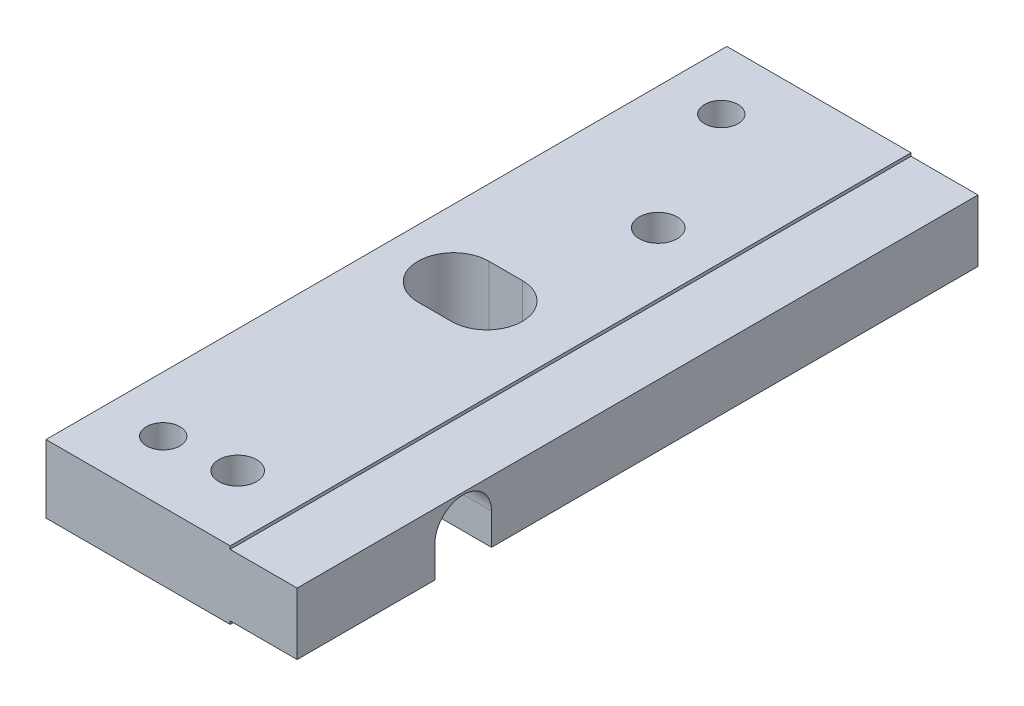
from build123d import *

# Parameters (mm, degrees)
SKETCH1_W                                        = 61
SKETCH1_H                                        = 6.1
BOSS_EXTRUDE1_DEPTH                              = 22.5
SKETCH2_OUTSIDE_W                                = 76.06
SKETCH2_OUTSIDE_H                                = 21.16
SKETCH2_OUTSIDE_W_2                              = 61
SKETCH2_OUTSIDE_H_2                              = 5.55
CUT_EXTRUDE1_DEPTH                               = 6
CUT_EXTRUDE3_DEPTH                               = 23.5
CUT_EXTRUDE4_DEPTH                               = 7.1
SKETCH7_R                                        = 1.5
CUT_EXTRUDE5_DEPTH                               = 7.1
CBORE_FOR_M3_PAN_HEAD_MACHINE_SCREW2_D           = 3.4
CBORE_FOR_M3_PAN_HEAD_MACHINE_SCREW2_CBORE_D     = 6.5
CBORE_FOR_M3_PAN_HEAD_MACHINE_SCREW2_CBORE_DEPTH = 2.2


with BuildPart() as part:
    # Sketch1 → Boss-Extrude1 (new body)
    with BuildSketch(Plane(origin=(0, 0, 0), x_dir=(0, 0, -1), z_dir=(1, 0, 0))):
        with Locations((30.5, 0)):
            Rectangle(SKETCH1_W, SKETCH1_H)
    extrude(amount=BOSS_EXTRUDE1_DEPTH)

    # Sketch2 outside → Cut-Extrude1 (cut)
    with BuildSketch(Plane(origin=(22.5, 0, 0), x_dir=(0, 0, -1), z_dir=(1, 0, 0))):
        with Locations((30.5, 0)):
            Rectangle(SKETCH2_OUTSIDE_W, SKETCH2_OUTSIDE_H)
        with Locations((30.5, 0)):
            Rectangle(SKETCH2_OUTSIDE_W_2, SKETCH2_OUTSIDE_H_2, mode=Mode.SUBTRACT)
    extrude(amount=-CUT_EXTRUDE1_DEPTH, mode=Mode.SUBTRACT)

    # Sketch5 → Cut-Extrude3 (cut, through all)
    with BuildSketch(Plane.ZY):
        with BuildLine():
            Line((-12.3486, 0.0496), (-12.3486, -3.05))
            Line((-12.3486, -3.05), (-17.4134, -3.05))
            Line((-17.4134, -3.05), (-17.4134, 0.0496))
            ThreePointArc((-17.4134, 0.0496), (-14.881, 2.582), (-12.3486, 0.0496))
        make_face()
    extrude(amount=-CUT_EXTRUDE3_DEPTH, mode=Mode.SUBTRACT)

    # Sketch6 → Cut-Extrude4 (cut, through all)
    with BuildSketch(Plane(origin=(0, 3.05, 0), x_dir=(1, 0, 0), z_dir=(0, 1, 0))):
        with BuildLine():
            Line((9, 27.325), (6, 27.325))
            ThreePointArc((6, 27.325), (2.825, 30.5), (6, 33.675))
            Line((6, 33.675), (9, 33.675))
            ThreePointArc((9, 33.675), (12.175, 30.5), (9, 27.325))
        make_face()
    extrude(amount=-CUT_EXTRUDE4_DEPTH, mode=Mode.SUBTRACT)

    # Sketch7 → Cut-Extrude5 (cut, through all)
    with BuildSketch(Plane(origin=(0, 3.05, 0), x_dir=(1, 0, 0), z_dir=(0, 1, 0))):
        with Locations(Location((5, 55.5, 0), (0, 0, 270))):  # turned: the seam where the file's is
            Circle(SKETCH7_R)
        with Locations(Location((5, 5.5, 0), (0, 0, 270))):  # turned: the seam where the file's is
            Circle(SKETCH7_R)
    extrude(amount=-CUT_EXTRUDE5_DEPTH, mode=Mode.SUBTRACT)

    # CBORE for M3 Pan Head Machine Screw2 (through all)
    with Locations(Plane(origin=(0, -3.05, 0), x_dir=(-1, 0, 0), z_dir=(0, -1, 0))):
        with Locations((-11, 6.175), (-11, 43.85)):
            CounterBoreHole(CBORE_FOR_M3_PAN_HEAD_MACHINE_SCREW2_D / 2, CBORE_FOR_M3_PAN_HEAD_MACHINE_SCREW2_CBORE_D / 2, CBORE_FOR_M3_PAN_HEAD_MACHINE_SCREW2_CBORE_DEPTH)


solid = part.part
